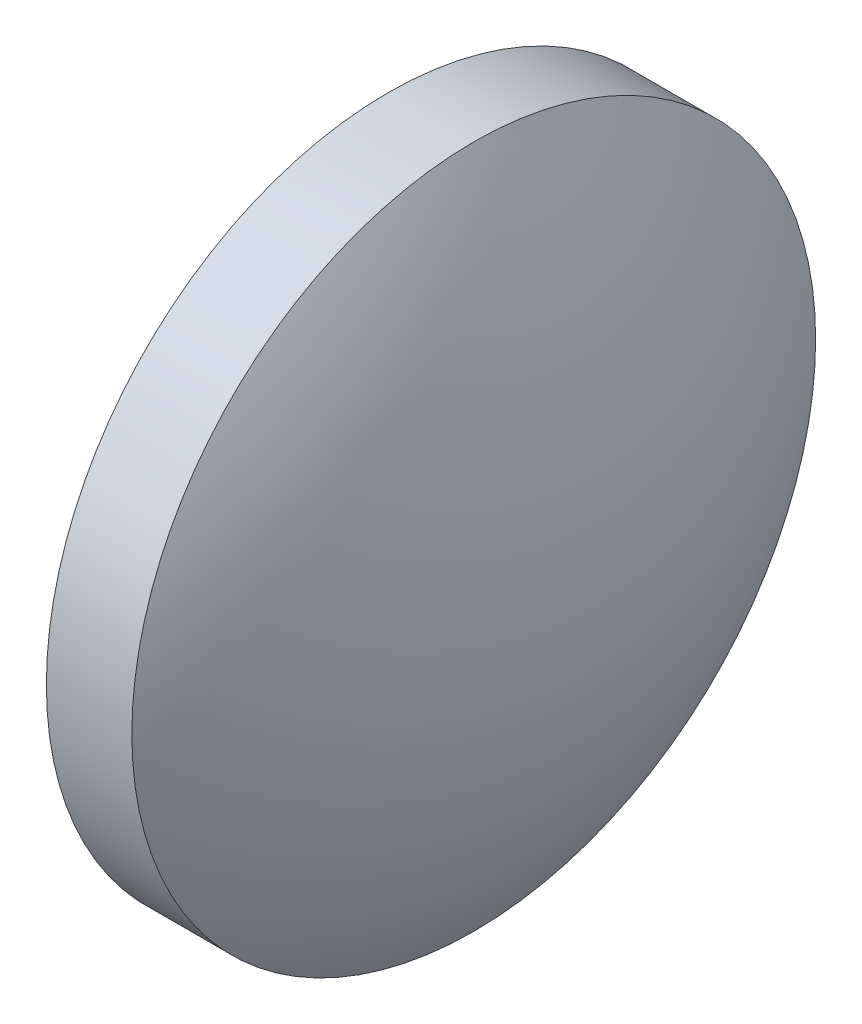
from build123d import *

# Parameters (mm, degrees)
SKETCH_1_ONE_SIDE_W = 2
SKETCH_1_ONE_SIDE_H = 8


with BuildPart() as part:
    # 草图1 one side → 旋转1 (revolve)
    with BuildSketch(Plane.XY, mode=Mode.PRIVATE) as revolve_1_sk:
        with Locations((54.461854346, 34.624323164)):
            Rectangle(SKETCH_1_ONE_SIDE_W, SKETCH_1_ONE_SIDE_H)
        with BuildLine():
            Line((51.206860061, 30.624323164), (53.461854346, 30.624323164))
            Line((53.461854346, 30.624323164), (53.461854346, 38.624323164))
            ThreePointArc((53.461854346, 38.624323164), (51.781382604, 34.780192484), (51.206860061, 30.624323164))
        make_face()
        with BuildLine():
            Line((55.461854346, 30.624323164), (57.716848632, 30.624323164))
            ThreePointArc((57.716848632, 30.624323164), (57.142326089, 34.780192484), (55.461854346, 38.624323164))
            Line((55.461854346, 38.624323164), (55.461854346, 30.624323164))
        make_face()
    revolve(revolve_1_sk.sketch.rotate(Axis((49.576455887, 30.624323164, 0), (1, 0, 0)), 180), axis=Axis((49.576455887, 30.624323164, 0), (1, 0, 0)))  # turned: the seam where the file's is


solid = part.part
